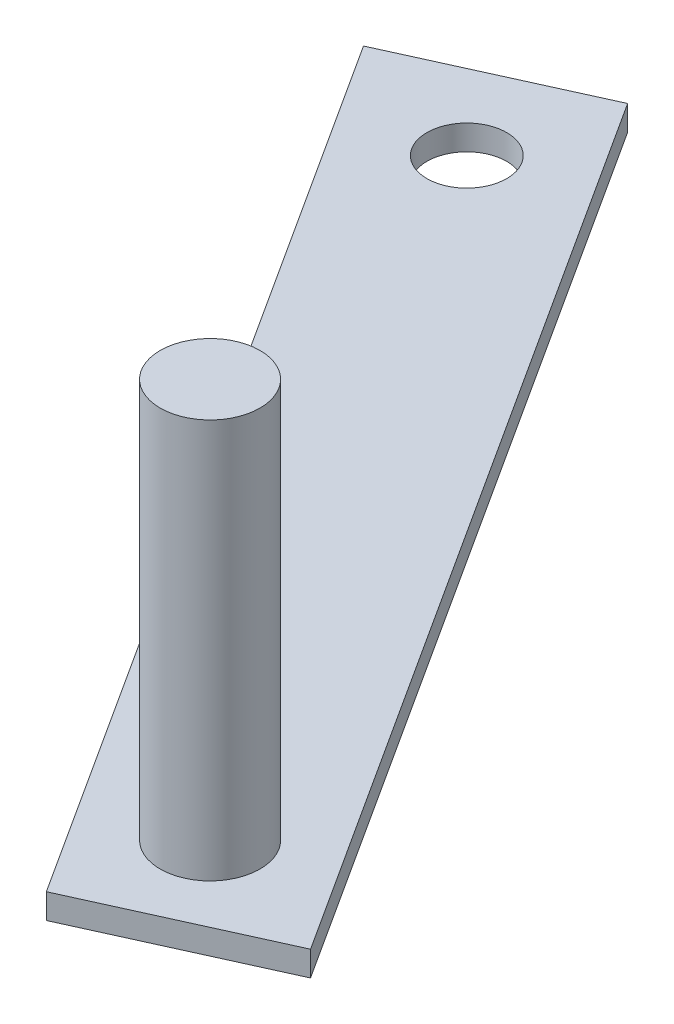
from build123d import *

# Parameters (mm, degrees)
SKETCH1_R           = 5.078298903
BOSS_EXTRUDE1_DEPTH = 3.175
SKETCH2_R           = 6.35
BOSS_EXTRUDE2_DEPTH = 50.8


with BuildPart() as part:
    # Sketch1 → Boss-Extrude1 (new body)
    with BuildSketch(Plane(origin=(0, 0, 0), x_dir=(1, 0, 0), z_dir=(0, 1, 0))):
        Polygon((-55.44099562, -40.268516884), (-128.460753109, 73.100956593), (-105.319843222, 83.572742001), (-32.300085734, -29.796731476), align=None)
        with Locations((-109.811555345, 67.600325735)):
            Circle(SKETCH1_R, mode=Mode.SUBTRACT)
    extrude(amount=BOSS_EXTRUDE1_DEPTH)

    # Sketch2 → Boss-Extrude2 (add)
    with BuildSketch(Plane(origin=(0, 3.175, 0), x_dir=(1, 0, 0), z_dir=(0, 1, 0))):
        with Locations((-50.696094851, -24.181527026)):
            Circle(SKETCH2_R)
    extrude(amount=BOSS_EXTRUDE2_DEPTH)


solid = part.part
